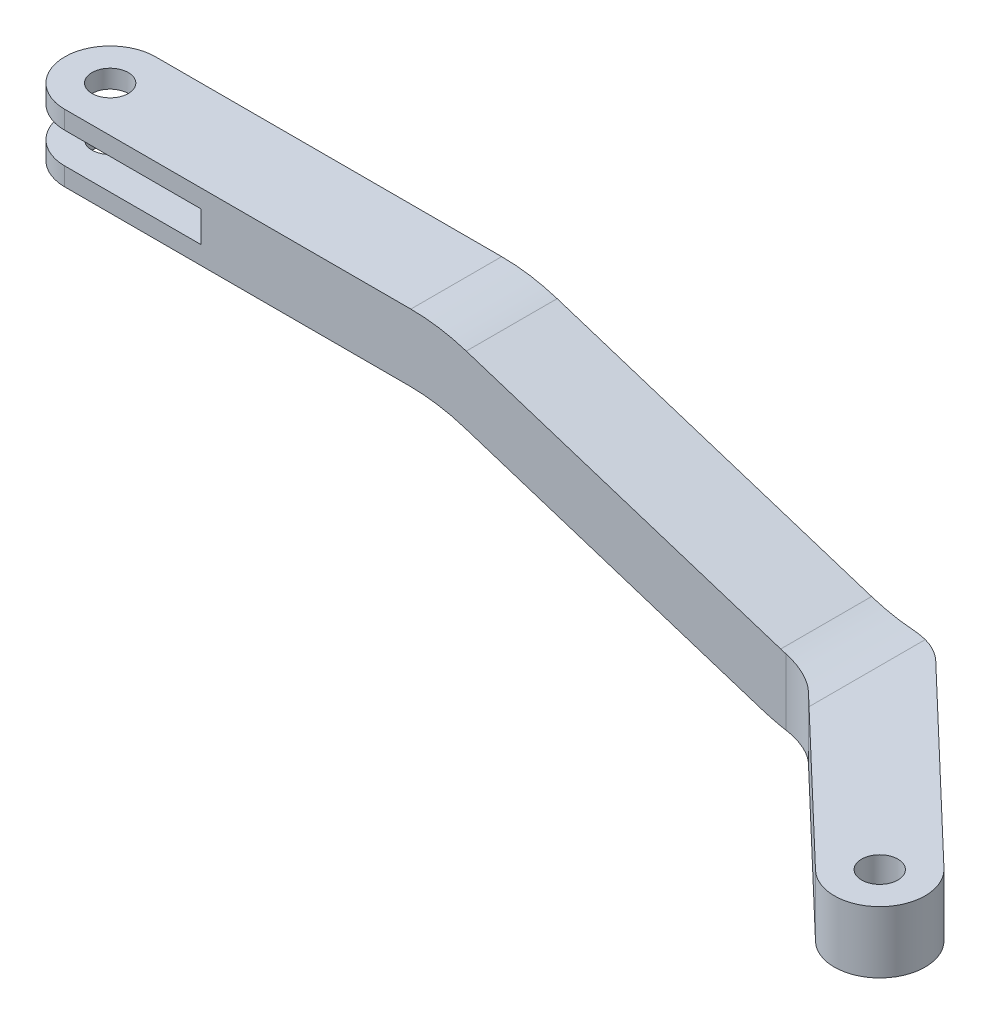
from build123d import *

# Parameters (mm, degrees)
BOSS_EXTRUDE1_DEPTH     = 2.5
BOSS_EXTRUDE2_DEPTH     = 3.4
CUT_EXTRUDE1_DEPTH      = 1
CUT_EXTRUDE1_DEPTH_BACK = 10.9
CUT_EXTRUDE2_DEPTH      = 10.810262799
CUT_EXTRUDE2_DEPTH_BACK = 6
SKETCH5_W               = 10
SKETCH5_H               = 1.7
CUT_EXTRUDE3_DEPTH      = 10.810262799
CUT_EXTRUDE3_DEPTH_BACK = 6
SKETCH6_R               = 1
CUT_EXTRUDE4_DEPTH      = 1
CUT_EXTRUDE4_DEPTH_BACK = 10.9
FILLET1_R               = 10
FILLET2_R               = 3


with BuildPart() as part:
    # Sketch1 → Boss-Extrude1 (new body, symmetric)
    with BuildSketch(Plane.XY):
        Polygon((-14.712036777, 6.5), (8.397963223, 6.5), (28.677963223, 0), (-14.712036777, 0), align=None)
    extrude(amount=BOSS_EXTRUDE1_DEPTH, both=True)

    # Sketch2 → Boss-Extrude2 (add)
    with BuildSketch(Plane.XZ):
        with BuildLine():
            Line((-12.212036777, -2.5), (30.682377195, -2.5))
            Line((30.682377195, -2.5), (41.676502177, 8.002543507))
            ThreePointArc((41.676502177, 8.002543507), (41.757330921, 11.537153346), (38.222721082, 11.617982091))
            Line((38.222721082, 11.617982091), (28.677963223, 2.5))
            Line((28.677963223, 2.5), (-12.212036777, 2.5))
            ThreePointArc((-12.212036777, 2.5), (-14.712036777, 0), (-12.212036777, -2.5))
        make_face()
    extrude(amount=BOSS_EXTRUDE2_DEPTH)

    # Sketch3 → Cut-Extrude1 (cut, two sides)
    with BuildSketch(Plane(origin=(0, 6.5, 0), x_dir=(1, 0, 0), z_dir=(0, 1, 0))) as cut_extrude1_sk:
        with BuildLine():
            ThreePointArc((-14.712036777, 0), (-13.97980373, 1.767766953), (-12.212036777, 2.5))
            Line((-12.212036777, 2.5), (-14.712036777, 2.5))
            Line((-14.712036777, 2.5), (-14.712036777, 0))
        make_face()
        with BuildLine():
            ThreePointArc((-12.212036777, -2.5), (-13.97980373, -1.767766953), (-14.712036777, 0))
            Line((-14.712036777, 0), (-14.712036777, -2.5))
            Line((-14.712036777, -2.5), (-12.212036777, -2.5))
        make_face()
    extrude(amount=CUT_EXTRUDE1_DEPTH, mode=Mode.SUBTRACT)
    extrude(cut_extrude1_sk.sketch, amount=-CUT_EXTRUDE1_DEPTH_BACK, mode=Mode.SUBTRACT)

    # Sketch4 → Cut-Extrude2 (cut, two sides)
    with BuildSketch(Plane.XY.offset(2.5)) as cut_extrude2_sk:
        Polygon((-14.712036777, 2.8), (8.310958279, 2.8), (27.654958279, -3.4), (-14.712036777, -3.4), align=None)
    extrude(amount=CUT_EXTRUDE2_DEPTH, mode=Mode.SUBTRACT)
    extrude(cut_extrude2_sk.sketch, amount=-CUT_EXTRUDE2_DEPTH_BACK, mode=Mode.SUBTRACT)

    # Sketch5 → Cut-Extrude3 (cut, two sides)
    with BuildSketch(Plane.XY.offset(2.5)) as cut_extrude3_sk:
        with Locations((-9.712036777, 4.65)):
            Rectangle(SKETCH5_W, SKETCH5_H)
    extrude(amount=CUT_EXTRUDE3_DEPTH, mode=Mode.SUBTRACT)
    extrude(cut_extrude3_sk.sketch, amount=-CUT_EXTRUDE3_DEPTH_BACK, mode=Mode.SUBTRACT)

    # Sketch6 → Cut-Extrude4 (cut, two sides)
    with BuildSketch(Plane(origin=(0, 6.5, 0), x_dir=(1, 0, 0), z_dir=(0, 1, 0))) as cut_extrude4_sk:
        with Locations((-12.212036777, 0)):
            Circle(SKETCH6_R)
        with Locations((39.94961163, -9.810262799)):
            Circle(SKETCH6_R)
    extrude(amount=CUT_EXTRUDE4_DEPTH, mode=Mode.SUBTRACT)
    extrude(cut_extrude4_sk.sketch, amount=-CUT_EXTRUDE4_DEPTH_BACK, mode=Mode.SUBTRACT)

    # Fillet1
    fillet1_edges = [part.edges().sort_by_distance(p)[0] for p in [
        (28.677963223, 0, 0),
        (8.397963223, 6.5, 0),
        (27.654958279, -3.4, 0),
        (8.310958279, 2.8, 0),
    ]]
    fillet(fillet1_edges, radius=FILLET1_R)

    # Fillet2
    fillet2_edges = [part.edges().sort_by_distance(p)[0] for p in [
        (30.682377195, -1.7, -2.5),
        (28.677963223, -1.631211096, 2.5),
    ]]
    fillet(fillet2_edges, radius=FILLET2_R)


solid = part.part
